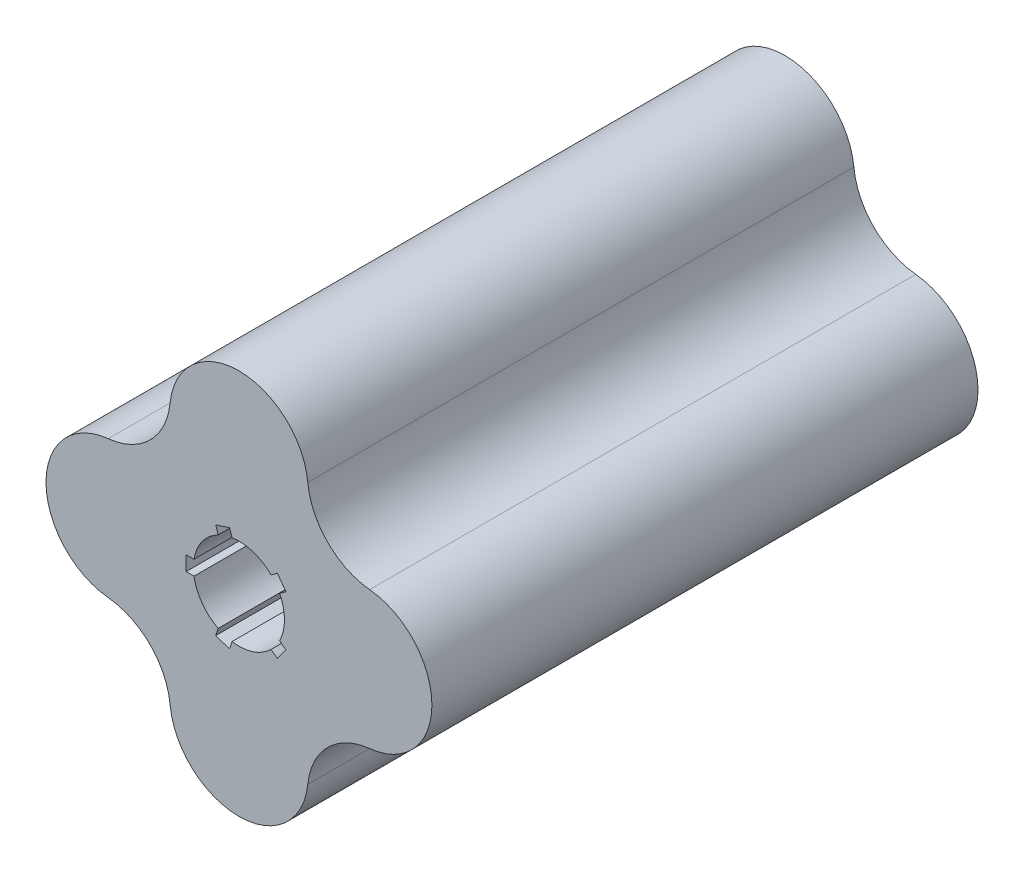
from build123d import *

# Parameters (mm, degrees)
SKETCH1_R           = 12.5
SKETCH1_R_2         = 19
BOSS_EXTRUDE1_DEPTH = 150
SKETCH2_W           = 4
SKETCH2_H           = 4
CUT_EXTRUDE1_DEPTH  = 151
CIRPATTERN1_COUNT   = 5


with BuildPart() as part:
    # Sketch1 → Boss-Extrude1 (new body)
    with BuildSketch(Plane.XY):
        with BuildLine():
            ThreePointArc((35.904326013, -18.904326024), (15, 0), (35.904326013, 18.904326024))
            ThreePointArc((35.904326013, 18.904326024), (24.373623204, 24.373623204), (18.904326024, 35.904326013))
            ThreePointArc((18.904326024, 35.904326013), (18.976066432, 34.953363922), (19, 34))
            ThreePointArc((19, 34), (-0.953363922, 15.023933568), (-18.904326024, 35.904326013))
            ThreePointArc((-18.904326024, 35.904326013), (-24.373623204, 24.373623204), (-35.904326013, 18.904326024))
            ThreePointArc((-35.904326013, 18.904326024), (-21.25602484, 14.092235349), (-15, 0))
            ThreePointArc((-15, 0), (-21.25602484, -14.092235349), (-35.904326013, -18.904326024))
            ThreePointArc((-35.904326013, -18.904326024), (-24.373623204, -24.373623204), (-18.904326024, -35.904326013))
            ThreePointArc((-18.904326024, -35.904326013), (-0.953363922, -15.023933568), (19, -34))
            ThreePointArc((19, -34), (18.976066432, -34.953363922), (18.904326024, -35.904326013))
            ThreePointArc((18.904326024, -35.904326013), (24.373623204, -24.373623204), (35.904326013, -18.904326024))
        make_face()
        Circle(SKETCH1_R, mode=Mode.SUBTRACT)
        with Locations((0, 34)):
            Circle(SKETCH1_R_2)
        with Locations((-34, 0)):
            Circle(SKETCH1_R_2)
        with Locations((0, -34)):
            Circle(SKETCH1_R_2)
        with Locations((34, 0)):
            Circle(SKETCH1_R_2)
    extrude(amount=BOSS_EXTRUDE1_DEPTH)

    # Sketch2 → Cut-Extrude1 (cut, through all)
    with BuildSketch(Plane(origin=(0, 0, 0), x_dir=(-1, 0, 0), z_dir=(0, 0, -1))):
        with Locations((12.5, 0)):
            Rectangle(SKETCH2_W, SKETCH2_H)
    cut_extrude1 = extrude(amount=-CUT_EXTRUDE1_DEPTH, mode=Mode.SUBTRACT)

    # CirPattern1: Cut-Extrude1 ×5 about axis
    cirpattern1_axis = Axis((0, 0, 0), (0, 0, 1))
    for i in range(1, CIRPATTERN1_COUNT):
        add(cut_extrude1.rotate(cirpattern1_axis, i * 360 / CIRPATTERN1_COUNT), mode=Mode.SUBTRACT)


solid = part.part
